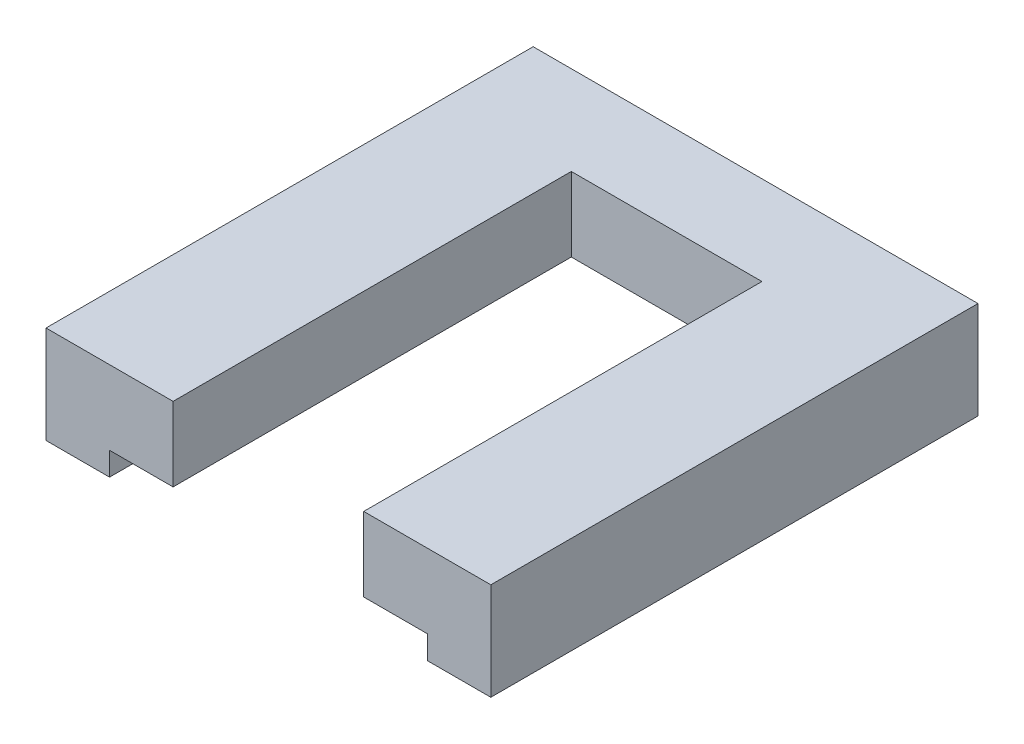
from build123d import *

# Parameters (mm, degrees)
BOSS_EXTRUDE1_DEPTH = 1.1
BOSS_EXTRUDE2_DEPTH = 3.5


with BuildPart() as part:
    # Sketch1 → Boss-Extrude1 (new body)
    with BuildSketch(Plane(origin=(0, 0, 0), x_dir=(1, 0, 0), z_dir=(0, 1, 0))):
        Polygon((9.705882353, 13.5), (-11.294117647, 13.5), (-11.294117647, -9.5), (-8.294117647, -9.5), (-8.294117647, 10.5), (6.705882353, 10.5), (6.705882353, -9.5), (9.705882353, -9.5), align=None)
    extrude(amount=BOSS_EXTRUDE1_DEPTH)

    # Sketch2 → Boss-Extrude2 (add)
    with BuildSketch(Plane(origin=(0, 1.1, 0), x_dir=(1, 0, 0), z_dir=(0, 1, 0))):
        Polygon((-8.294117647, -9.5), (-5.294117647, -9.5), (-5.294117647, 9.3), (3.705882353, 9.3), (3.705882353, -9.5), (6.705882353, -9.5), (9.705882353, -9.5), (9.705882353, 13.5), (-11.294117647, 13.5), (-11.294117647, -9.5), align=None)
    extrude(amount=BOSS_EXTRUDE2_DEPTH)


solid = part.part
